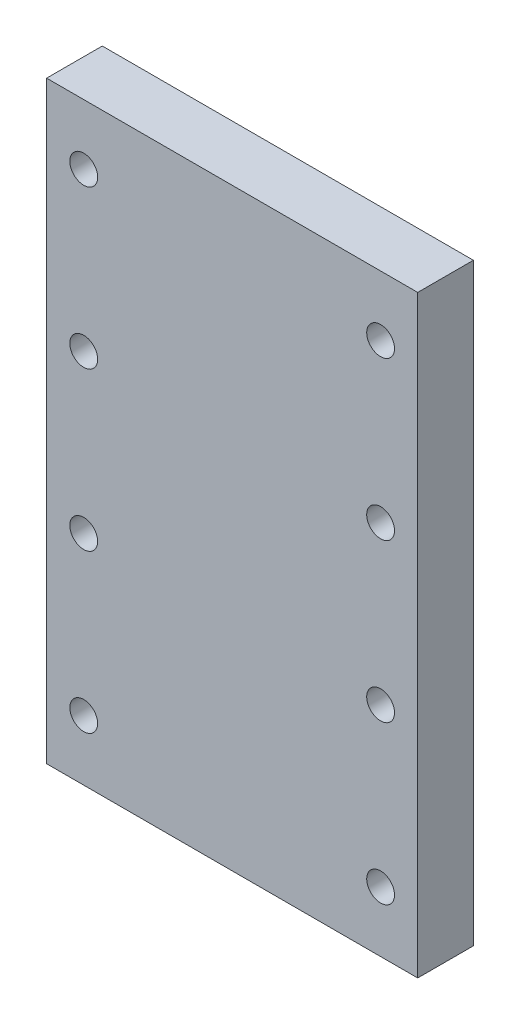
from build123d import *

# Parameters (mm, degrees)
SKETCH1_W               = 40
SKETCH1_H               = 64
BOSS_EXTRUDE1_DEPTH     = 6
SKETCH2_R               = 1.5
CUT_EXTRUDE1_DEPTH      = 1
CUT_EXTRUDE1_DEPTH_BACK = 7


with BuildPart() as part:
    # Sketch1 → Boss-Extrude1 (new body)
    with BuildSketch(Plane.XY):
        with Locations((-12.888888889, 35.555555556)):
            Rectangle(SKETCH1_W, SKETCH1_H)
    extrude(amount=BOSS_EXTRUDE1_DEPTH)

    # Sketch2 → Cut-Extrude1 (cut, two sides)
    with BuildSketch(Plane.XY.offset(6)) as cut_extrude1_sk:
        with Locations((-28.888888889, 10.055555556)):
            Circle(SKETCH2_R)
        with Locations((-28.888888889, 27.055555556)):
            Circle(SKETCH2_R)
        with Locations((-28.888888889, 44.055555556)):
            Circle(SKETCH2_R)
        with Locations((-28.888888889, 61.055555556)):
            Circle(SKETCH2_R)
        with Locations((3.111111111, 10.055555556)):
            Circle(SKETCH2_R)
        with Locations((3.111111111, 27.055555556)):
            Circle(SKETCH2_R)
        with Locations((3.111111111, 44.055555556)):
            Circle(SKETCH2_R)
        with Locations((3.111111111, 61.055555556)):
            Circle(SKETCH2_R)
    extrude(amount=CUT_EXTRUDE1_DEPTH, mode=Mode.SUBTRACT)
    extrude(cut_extrude1_sk.sketch, amount=-CUT_EXTRUDE1_DEPTH_BACK, mode=Mode.SUBTRACT)


solid = part.part
